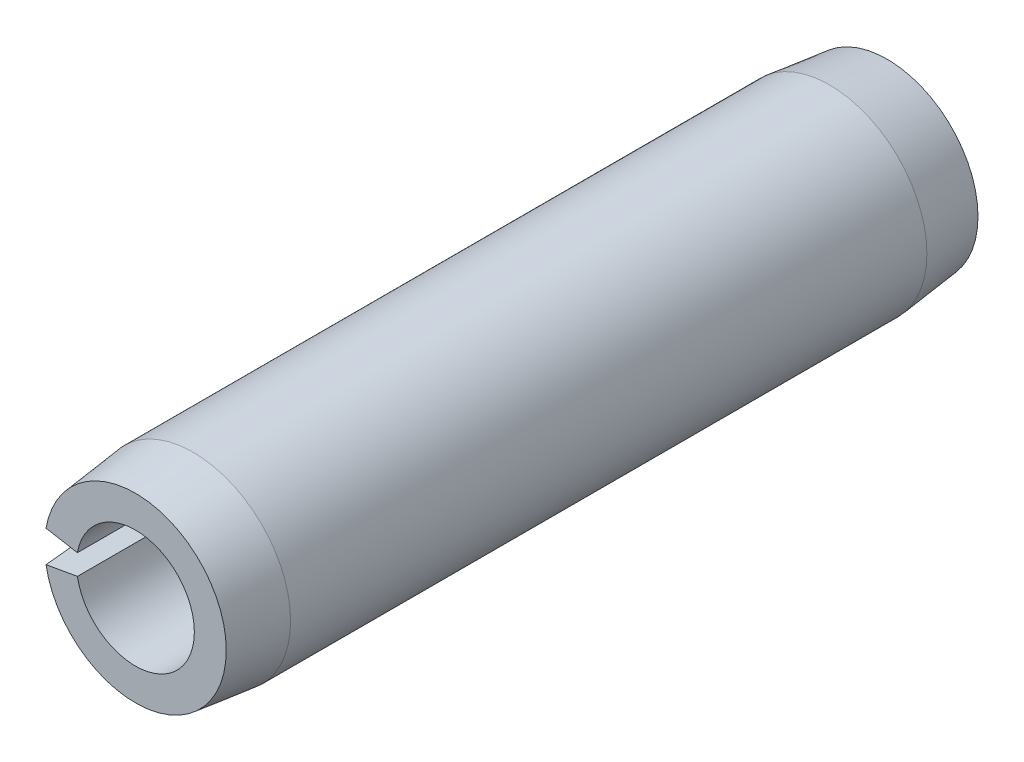
from build123d import *

# Parameters (mm, degrees)
EXTRUDE1_DEPTH = 7.9375


with BuildPart() as part:
    # Sketch1 → Extrude1 (new body, symmetric)
    with BuildSketch(Plane.XY):
        with BuildLine():
            Line((-2.026143471, 0.357263761), (-1.225691729, 0.216122522))
            ThreePointArc((-1.225691729, 0.216122522), (1.2446, 0), (-1.225691729, -0.216122522))
            Line((-1.225691729, -0.216122522), (-2.026143471, -0.357263761))
            ThreePointArc((-2.026143471, -0.357263761), (2.0574, 0), (-2.026143471, 0.357263761))
        make_face()
    extrude(amount=EXTRUDE1_DEPTH, both=True)

    # Sketch2 → Cut-Revolve1 (revolve, cut)
    with BuildSketch(Plane(origin=(0, 0, 0), x_dir=(0, 0, -1), z_dir=(1, 0, 0))):
        Polygon((7.9375, 2.0574), (7.9375, 1.9177), (6.7183, 2.0574), align=None)
        Polygon((-6.7183, 2.0574), (-7.9375, 2.0574), (-7.9375, 1.9177), align=None)
    revolve(axis=Axis((0, 0, -7.9375), (0, 0, 1)), mode=Mode.SUBTRACT)


solid = part.part
